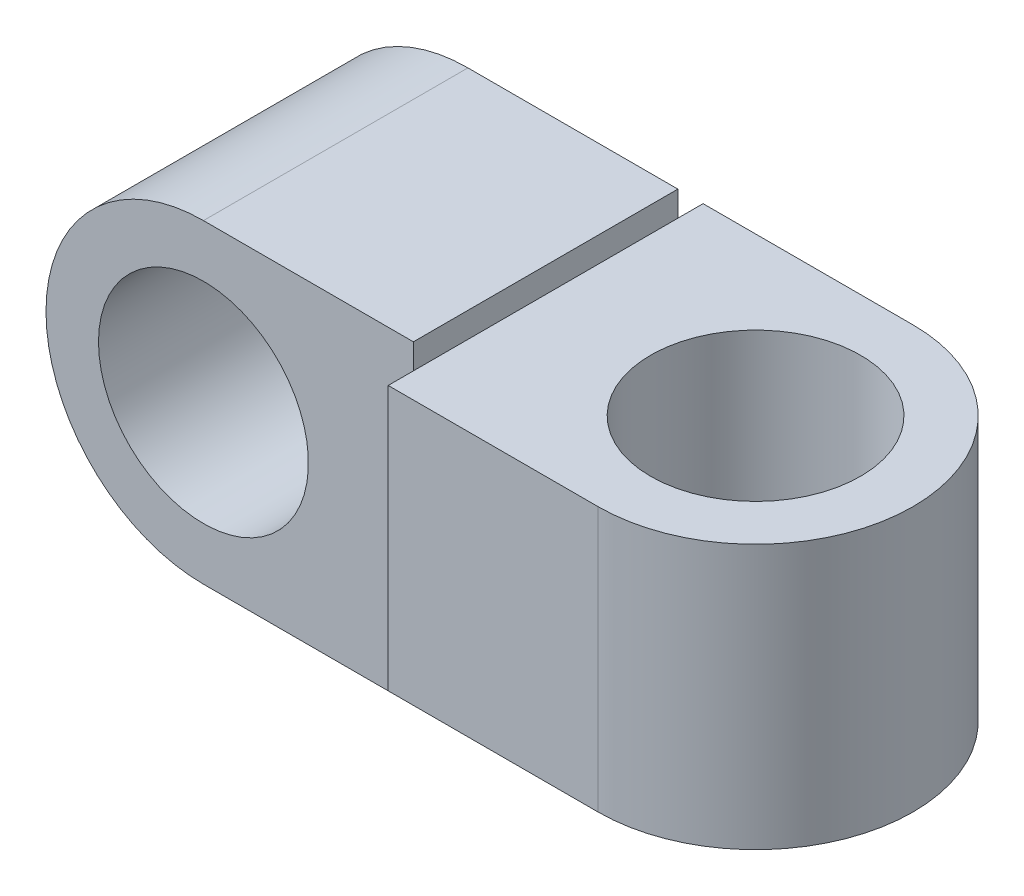
from build123d import *

# Parameters (mm, degrees)
SKETCH3_R           = 7.9375
BOSS_EXTRUDE2_DEPTH = 10
SKETCH4_R           = 11.90625
SKETCH4_R_2         = 7.9375
BOSS_EXTRUDE3_DEPTH = 10


with BuildPart() as part:
    # Sketch3 → Boss-Extrude2 (new, symmetric)
    with BuildSketch(Plane.XY):
        with BuildLine():
            Line((0, -11.90625), (0, 11.90625))
            Line((0, 11.90625), (-15.875, 11.90625))
            ThreePointArc((-15.875, 11.90625), (-27.78125, 0), (-15.875, -11.90625))
            Line((-15.875, -11.90625), (0, -11.90625))
        make_face()
        with Locations((-15.875, 0)):
            Circle(SKETCH3_R, mode=Mode.SUBTRACT)
    extrude(amount=BOSS_EXTRUDE2_DEPTH, both=True)

    # Sketch4 → Boss-Extrude3 (add, symmetric)
    with BuildSketch(Plane(origin=(0, 0, 0), x_dir=(1, 0, 0), z_dir=(0, 1, 0))):
        with Locations((15.875, 0)):
            Circle(SKETCH4_R)
        with Locations(Location((15.875, 0, 0), (0, 0, 270))):
            Circle(SKETCH4_R_2, mode=Mode.SUBTRACT)
        with BuildLine():
            Line((0, -11.90625), (15.875, -11.90625))
            ThreePointArc((15.875, -11.90625), (3.96875, 0), (15.875, 11.90625))
            Line((15.875, 11.90625), (0, 11.90625))
            Line((0, 11.90625), (0, -11.90625))
        make_face()
    extrude(amount=BOSS_EXTRUDE3_DEPTH, both=True)


solid = part.part
